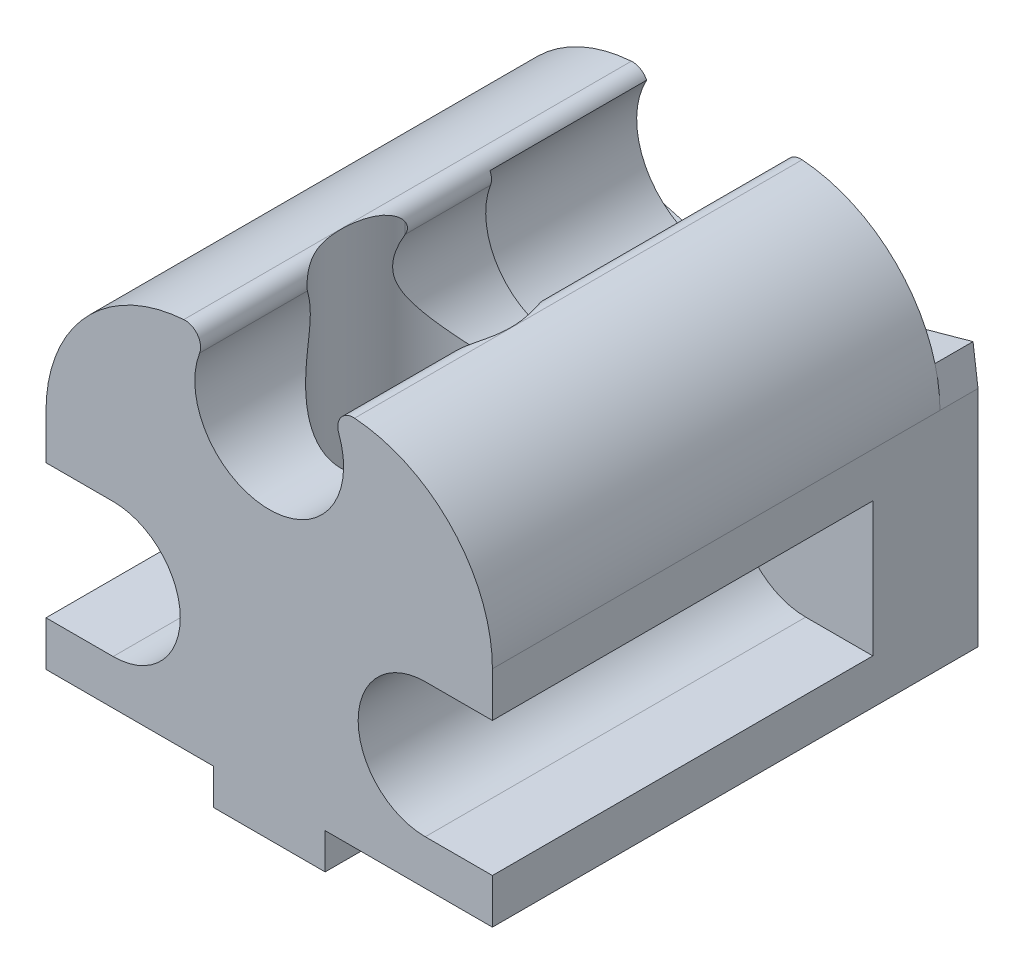
from build123d import *

# Parameters (mm, degrees)
BOSS_EXTRUDE1_DEPTH = 20
SKETCH2_W           = 5
SKETCH2_H           = 1.6
BOSS_EXTRUDE2_DEPTH = 13
SKETCH3_R           = 3.578569403
CUT_EXTRUDE1_DEPTH  = 7
BOSS_EXTRUDE3_DEPTH = 1.7
CUT_EXTRUDE2_START  = 20
SKETCH6_R           = 2.25
CUT_EXTRUDE2_DEPTH  = 22.6
CUT_EXTRUDE3_START  = 3
SKETCH7_R           = 3.8
CUT_EXTRUDE3_DEPTH  = 14.622368421
SKETCH8_R           = 1.65
CUT_EXTRUDE4_DEPTH  = 40
CUT_EXTRUDE5_DEPTH  = 17
SKETCH10_R          = 1.65
BOSS_EXTRUDE4_DEPTH = 0.2


with BuildPart() as part:
    # Sketch1 → Boss-Extrude1 (new body)
    with BuildSketch(Plane.XY):
        with BuildLine():
            Line((-9.975, 0), (9.975, 0))
            Line((9.975, 0), (9.975, 10))
            ThreePointArc((9.975, 10), (8.197090719, 14.521275434), (3.815771997, 16.620546549))
            ThreePointArc((3.815771997, 16.620546549), (3.204205313, 16.340903263), (3.110466203, 15.675))
            ThreePointArc((3.110466203, 15.675), (0, 11.175), (-3.110466203, 15.675))
            ThreePointArc((-3.110466203, 15.675), (-3.204205313, 16.340903263), (-3.815771997, 16.620546549))
            ThreePointArc((-3.815771997, 16.620546549), (-8.197090719, 14.521275434), (-9.975, 10))
            Line((-9.975, 10), (-9.975, 0))
        make_face()
    extrude(amount=BOSS_EXTRUDE1_DEPTH)

    # Sketch2 → Boss-Extrude2 (add)
    with BuildSketch(Plane.XY.offset(20)):
        with Locations((0, -0.8)):
            Rectangle(SKETCH2_W, SKETCH2_H)
    extrude(amount=-BOSS_EXTRUDE2_DEPTH)

    # Sketch3 → Cut-Extrude1 (cut)
    with BuildSketch(Plane(origin=(0, 0, 0), x_dir=(-1, 0, 0), z_dir=(0, 0, -1))):
        with Locations((0, 14.5)):
            Circle(SKETCH3_R)
    extrude(amount=-CUT_EXTRUDE1_DEPTH, mode=Mode.SUBTRACT)

    # Sketch4 → Boss-Extrude3 (add)
    with BuildSketch(Plane(origin=(0, 0, 0), x_dir=(-1, 0, 0), z_dir=(0, 0, -1))):
        with BuildLine():
            Line((-9.975, 0), (-9.975, 10))
            Line((-9.975, 10), (-9.752890248, 11.702738246))
            Line((-9.752890248, 11.702738246), (-1.415257539, 9.392452047))
            ThreePointArc((-1.415257539, 9.392452047), (0, 9.2), (1.415257539, 9.392452047))
            Line((1.415257539, 9.392452047), (9.752890248, 11.702738246))
            Line((9.752890248, 11.702738246), (9.975, 10))
            Line((9.975, 10), (9.975, 0))
            Line((9.975, 0), (-9.975, 0))
        make_face()
    extrude(amount=BOSS_EXTRUDE3_DEPTH)

    # Sketch6 → Cut-Extrude2 (cut, through all)
    with BuildSketch(Plane(origin=(0, 0, 0), x_dir=(1, 0, 0), z_dir=(0, 1, 0)).offset(CUT_EXTRUDE2_START)):
        with Locations((0, -13)):
            Circle(SKETCH6_R)
    extrude(amount=-CUT_EXTRUDE2_DEPTH, mode=Mode.SUBTRACT)

    # Sketch7 → Cut-Extrude3 (cut, through all)
    with BuildSketch(Plane(origin=(0, 0, 0), x_dir=(1, 0, 0), z_dir=(0, 1, 0)).offset(CUT_EXTRUDE3_START)):
        with Locations((0, -13)):
            Circle(SKETCH7_R)
    extrude(amount=CUT_EXTRUDE3_DEPTH, mode=Mode.SUBTRACT)

    # Sketch8 → Cut-Extrude4 (cut)
    with BuildSketch(Plane(origin=(0, 0, -1.7), x_dir=(-1, 0, 0), z_dir=(0, 0, -1))):
        with Locations((6.975, 5)):
            Circle(SKETCH8_R)
    cut_extrude4 = extrude(amount=-CUT_EXTRUDE4_DEPTH, mode=Mode.SUBTRACT)

    # Mirror1: Cut-Extrude4 across plane
    add(cut_extrude4.mirror(Plane(origin=(0, 0, 0), x_dir=(0, 0, 1), z_dir=(1, 0, 0))), mode=Mode.SUBTRACT)

    # Sketch9 → Cut-Extrude5 (cut)
    with BuildSketch(Plane.XY.offset(20)):
        with BuildLine():
            Line((-6.975, 8), (-9.975, 8))
            Line((-9.975, 8), (-9.975, 2))
            Line((-9.975, 2), (-6.975, 2))
            ThreePointArc((-6.975, 2), (-3.975, 5), (-6.975, 8))
        make_face()
    cut_extrude5 = extrude(amount=-CUT_EXTRUDE5_DEPTH, mode=Mode.SUBTRACT)

    # Sketch10 → Boss-Extrude4 (add)
    with BuildSketch(Plane.XY.offset(3)):
        with Locations((-6.975, 5)):
            Circle(SKETCH10_R)
    boss_extrude4 = extrude(amount=-BOSS_EXTRUDE4_DEPTH)

    # Mirror2: Cut-Extrude5, Boss-Extrude4 across plane
    add(cut_extrude5.mirror(Plane(origin=(0, 0, 0), x_dir=(0, 0, 1), z_dir=(1, 0, 0))), mode=Mode.SUBTRACT)
    add(boss_extrude4.mirror(Plane(origin=(0, 0, 0), x_dir=(0, 0, 1), z_dir=(1, 0, 0))))


solid = part.part
